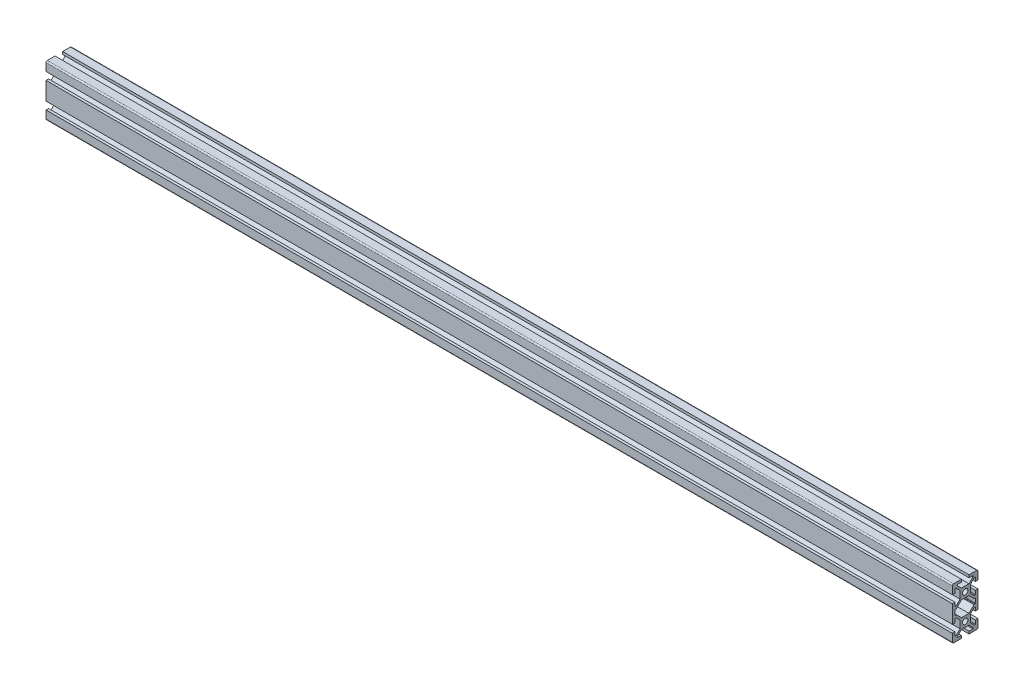
from build123d import *

# Parameters (mm, degrees)
SKETCH1_R           = 2.1
BOSS_EXTRUDE1_DEPTH = 707


with BuildPart() as part:
    # Sketch1 → Boss-Extrude1 (new body)
    with BuildSketch(Plane(origin=(0, 0, 0), x_dir=(0, 0, -1), z_dir=(1, 0, 0))):
        with BuildLine():
            Line((-10, -13), (-10, -19))
            ThreePointArc((-10, -19), (-9.707106781, -19.707106781), (-9, -20))
            Line((-9, -20), (-3, -20))
            Line((-3, -20), (-3, -18))
            Line((-3, -18), (-6, -18))
            Line((-6, -18), (-6, -17.060660172))
            Line((-6, -17.060660172), (-2.939339828, -14))
            Line((-2.939339828, -14), (2.939339828, -14))
            Line((2.939339828, -14), (6, -17.060660172))
            Line((6, -17.060660172), (6, -18))
            Line((6, -18), (3, -18))
            Line((3, -18), (3, -20))
            Line((3, -20), (9, -20))
            ThreePointArc((9, -20), (9.707106781, -19.707106781), (10, -19))
            Line((10, -19), (10, -13))
            Line((10, -13), (8, -13))
            Line((8, -13), (8, -16))
            Line((8, -16), (7.060660172, -16))
            Line((7.060660172, -16), (4, -12.939339828))
            Line((4, -12.939339828), (4, -7.060660172))
            Line((4, -7.060660172), (7.060660172, -4))
            Line((7.060660172, -4), (8, -4))
            Line((8, -4), (8, -7))
            Line((8, -7), (10, -7))
            Line((10, -7), (10, 7))
            Line((10, 7), (8, 7))
            Line((8, 7), (8, 4))
            Line((8, 4), (7.060660172, 4))
            Line((7.060660172, 4), (4, 7.060660172))
            Line((4, 7.060660172), (4, 12.939339828))
            Line((4, 12.939339828), (7.060660172, 16))
            Line((7.060660172, 16), (8, 16))
            Line((8, 16), (8, 13))
            Line((8, 13), (10, 13))
            Line((10, 13), (10, 19))
            ThreePointArc((10, 19), (9.707106781, 19.707106781), (9, 20))
            Line((9, 20), (3, 20))
            Line((3, 20), (3, 18))
            Line((3, 18), (6, 18))
            Line((6, 18), (6, 17.060660172))
            Line((6, 17.060660172), (2.939339828, 14))
            Line((2.939339828, 14), (-2.939339828, 14))
            Line((-2.939339828, 14), (-6, 17.060660172))
            Line((-6, 17.060660172), (-6, 18))
            Line((-6, 18), (-3, 18))
            Line((-3, 18), (-3, 20))
            Line((-3, 20), (-9, 20))
            ThreePointArc((-9, 20), (-9.707106781, 19.707106781), (-10, 19))
            Line((-10, 19), (-10, 13))
            Line((-10, 13), (-8, 13))
            Line((-8, 13), (-8, 16))
            Line((-8, 16), (-7.060660172, 16))
            Line((-7.060660172, 16), (-4, 12.939339828))
            Line((-4, 12.939339828), (-4, 7.060660172))
            Line((-4, 7.060660172), (-7.060660172, 4))
            Line((-7.060660172, 4), (-8, 4))
            Line((-8, 4), (-8, 7))
            Line((-8, 7), (-10, 7))
            Line((-10, 7), (-10, -7))
            Line((-10, -7), (-8, -7))
            Line((-8, -7), (-8, -4))
            Line((-8, -4), (-7.060660172, -4))
            Line((-7.060660172, -4), (-4, -7.060660172))
            Line((-4, -7.060660172), (-4, -12.939339828))
            Line((-4, -12.939339828), (-7.060660172, -16))
            Line((-7.060660172, -16), (-8, -16))
            Line((-8, -16), (-8, -13))
            Line((-8, -13), (-10, -13))
        make_face()
        with Locations((0, 10)):
            Circle(SKETCH1_R, mode=Mode.SUBTRACT)
        with Locations((0, -10)):
            Circle(SKETCH1_R, mode=Mode.SUBTRACT)
        with BuildLine():
            Line((-8, 1.7), (-8, -1.7))
            ThreePointArc((-8, -1.7), (-7.912132034, -1.912132034), (-7.7, -2))
            Line((-7.7, -2), (-7.063603897, -2))
            ThreePointArc((-7.063603897, -2), (-6.948798867, -2.02283614), (-6.851471863, -2.087867966))
            Line((-6.851471863, -2.087867966), (-2.939339828, -6))
            Line((-2.939339828, -6), (2.939339828, -6))
            Line((2.939339828, -6), (6.851471863, -2.087867966))
            ThreePointArc((6.851471863, -2.087867966), (6.948798867, -2.02283614), (7.063603897, -2))
            Line((7.063603897, -2), (7.7, -2))
            ThreePointArc((7.7, -2), (7.912132034, -1.912132034), (8, -1.7))
            Line((8, -1.7), (8, 1.7))
            ThreePointArc((8, 1.7), (7.912132034, 1.912132034), (7.7, 2))
            Line((7.7, 2), (7.063603897, 2))
            ThreePointArc((7.063603897, 2), (6.948798867, 2.02283614), (6.851471863, 2.087867966))
            Line((6.851471863, 2.087867966), (2.939339828, 6))
            Line((2.939339828, 6), (-2.939339828, 6))
            Line((-2.939339828, 6), (-6.851471863, 2.087867966))
            ThreePointArc((-6.851471863, 2.087867966), (-6.948798867, 2.02283614), (-7.063603897, 2))
            Line((-7.063603897, 2), (-7.7, 2))
            ThreePointArc((-7.7, 2), (-7.912132034, 1.912132034), (-8, 1.7))
        make_face(mode=Mode.SUBTRACT)
    extrude(amount=BOSS_EXTRUDE1_DEPTH)


solid = part.part
